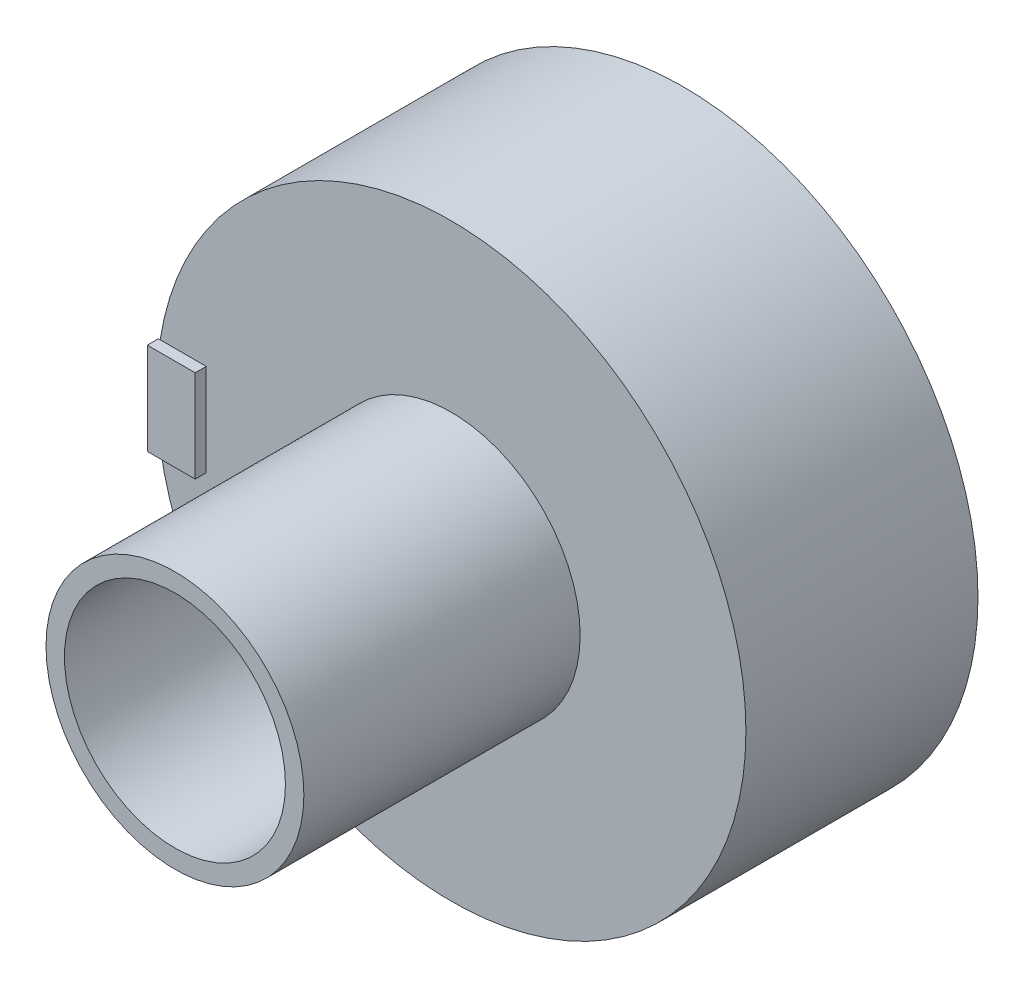
from build123d import *

# Parameters (mm, degrees)
SKETCH1_R           = 8
BOSS_EXTRUDE1_DEPTH = 6.3
SKETCH2_R           = 3.5
BOSS_EXTRUDE2_DEPTH = 7.5
SKETCH3_R           = 3
CUT_EXTRUDE1_DEPTH  = 7.5
SKETCH5_W           = 1.3
SKETCH5_H           = 2.5
BOSS_EXTRUDE3_DEPTH = 0.3


with BuildPart() as part:
    # Sketch1 → Boss-Extrude1 (new body)
    with BuildSketch(Plane.XY):
        Circle(SKETCH1_R)
    extrude(amount=BOSS_EXTRUDE1_DEPTH)

    # Sketch2 → Boss-Extrude2 (add)
    with BuildSketch(Plane.XY.offset(6.3)):
        Circle(SKETCH2_R)
    extrude(amount=BOSS_EXTRUDE2_DEPTH)

    # Sketch3 → Cut-Extrude1 (cut)
    with BuildSketch(Plane.XY.offset(13.8)):
        Circle(SKETCH3_R)
    extrude(amount=-CUT_EXTRUDE1_DEPTH, mode=Mode.SUBTRACT)

    # Sketch5 → Boss-Extrude3 (add)
    with BuildSketch(Plane.XY.offset(6.3)):
        with Locations((-7.3, 0)):
            Rectangle(SKETCH5_W, SKETCH5_H)
    extrude(amount=BOSS_EXTRUDE3_DEPTH)


solid = part.part
